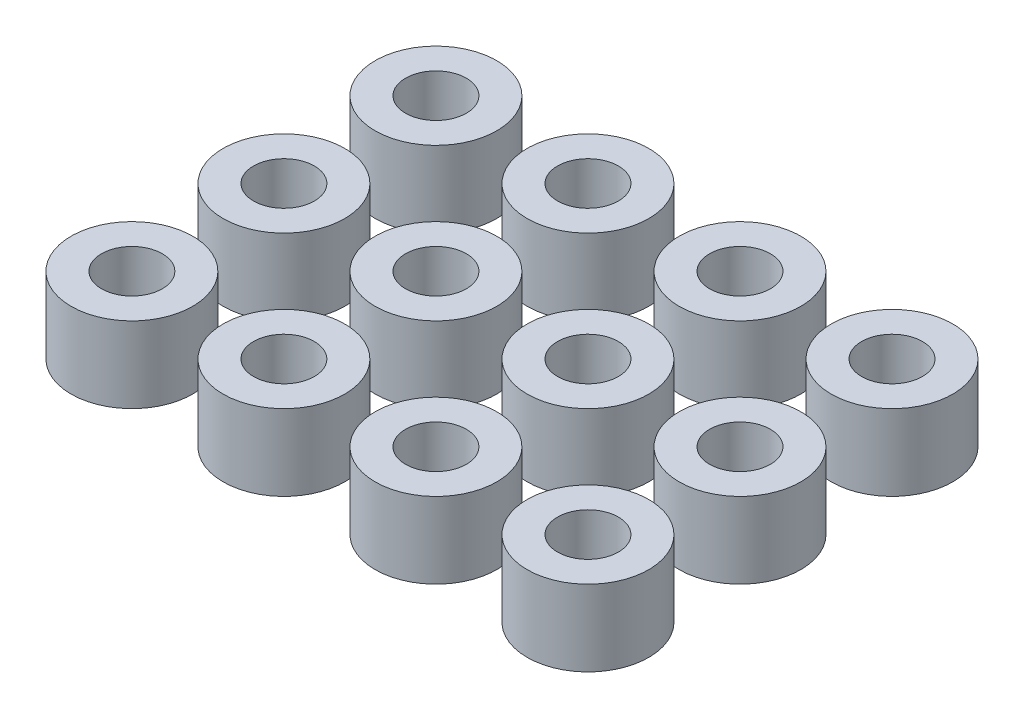
from build123d import *

# Parameters (mm, degrees)
SKETCH1_R              = 4
SKETCH1_R_2            = 2
BOSS_EXTRUDE1_DEPTH    = 5
BOSS_EXTRUDE1_2_DEPTH  = 5
BOSS_EXTRUDE1_3_DEPTH  = 5
BOSS_EXTRUDE1_4_DEPTH  = 5
BOSS_EXTRUDE1_5_DEPTH  = 5
BOSS_EXTRUDE1_6_DEPTH  = 5
BOSS_EXTRUDE1_7_DEPTH  = 5
BOSS_EXTRUDE1_8_DEPTH  = 5
BOSS_EXTRUDE1_9_DEPTH  = 5
BOSS_EXTRUDE1_10_DEPTH = 5
BOSS_EXTRUDE1_11_DEPTH = 5
BOSS_EXTRUDE1_12_DEPTH = 5


with BuildPart() as part:
    # Sketch1 → Boss-Extrude1 (new body)
    with BuildSketch(Plane(origin=(0, 0, 0), x_dir=(1, 0, 0), z_dir=(0, 1, 0))):
        with Locations((-15, -10)):
            Circle(SKETCH1_R)
        with Locations((-15, -10)):
            Circle(SKETCH1_R_2, mode=Mode.SUBTRACT)
    extrude(amount=BOSS_EXTRUDE1_DEPTH)


with BuildPart() as body_2:
    # Sketch1 → Boss-Extrude1 2 (new body)
    with BuildSketch(Plane(origin=(0, 0, 0), x_dir=(1, 0, 0), z_dir=(0, 1, 0))):
        with Locations((-5, -10)):
            Circle(SKETCH1_R)
        with Locations((-5, -10)):
            Circle(SKETCH1_R_2, mode=Mode.SUBTRACT)
    extrude(amount=BOSS_EXTRUDE1_2_DEPTH)


with BuildPart() as body_3:
    # Sketch1 → Boss-Extrude1 3 (new body)
    with BuildSketch(Plane(origin=(0, 0, 0), x_dir=(1, 0, 0), z_dir=(0, 1, 0))):
        with Locations((5, -10)):
            Circle(SKETCH1_R)
        with Locations((5, -10)):
            Circle(SKETCH1_R_2, mode=Mode.SUBTRACT)
    extrude(amount=BOSS_EXTRUDE1_3_DEPTH)


with BuildPart() as body_4:
    # Sketch1 → Boss-Extrude1 4 (new body)
    with BuildSketch(Plane(origin=(0, 0, 0), x_dir=(1, 0, 0), z_dir=(0, 1, 0))):
        with Locations((15, -10)):
            Circle(SKETCH1_R)
        with Locations((15, -10)):
            Circle(SKETCH1_R_2, mode=Mode.SUBTRACT)
    extrude(amount=BOSS_EXTRUDE1_4_DEPTH)


with BuildPart() as body_5:
    # Sketch1 → Boss-Extrude1 5 (new body)
    with BuildSketch(Plane(origin=(0, 0, 0), x_dir=(1, 0, 0), z_dir=(0, 1, 0))):
        with Locations((-5, 0)):
            Circle(SKETCH1_R)
        with Locations((-5, 0)):
            Circle(SKETCH1_R_2, mode=Mode.SUBTRACT)
    extrude(amount=BOSS_EXTRUDE1_5_DEPTH)


with BuildPart() as body_6:
    # Sketch1 → Boss-Extrude1 6 (new body)
    with BuildSketch(Plane(origin=(0, 0, 0), x_dir=(1, 0, 0), z_dir=(0, 1, 0))):
        with Locations((5, 0)):
            Circle(SKETCH1_R)
        with Locations((5, 0)):
            Circle(SKETCH1_R_2, mode=Mode.SUBTRACT)
    extrude(amount=BOSS_EXTRUDE1_6_DEPTH)


with BuildPart() as body_7:
    # Sketch1 → Boss-Extrude1 7 (new body)
    with BuildSketch(Plane(origin=(0, 0, 0), x_dir=(1, 0, 0), z_dir=(0, 1, 0))):
        with Locations((15, 0)):
            Circle(SKETCH1_R)
        with Locations((15, 0)):
            Circle(SKETCH1_R_2, mode=Mode.SUBTRACT)
    extrude(amount=BOSS_EXTRUDE1_7_DEPTH)


with BuildPart() as body_8:
    # Sketch1 → Boss-Extrude1 8 (new body)
    with BuildSketch(Plane(origin=(0, 0, 0), x_dir=(1, 0, 0), z_dir=(0, 1, 0))):
        with Locations((-5, 10)):
            Circle(SKETCH1_R)
        with Locations((-5, 10)):
            Circle(SKETCH1_R_2, mode=Mode.SUBTRACT)
    extrude(amount=BOSS_EXTRUDE1_8_DEPTH)


with BuildPart() as body_9:
    # Sketch1 → Boss-Extrude1 9 (new body)
    with BuildSketch(Plane(origin=(0, 0, 0), x_dir=(1, 0, 0), z_dir=(0, 1, 0))):
        with Locations((5, 10)):
            Circle(SKETCH1_R)
        with Locations((5, 10)):
            Circle(SKETCH1_R_2, mode=Mode.SUBTRACT)
    extrude(amount=BOSS_EXTRUDE1_9_DEPTH)


with BuildPart() as body_10:
    # Sketch1 → Boss-Extrude1 10 (new body)
    with BuildSketch(Plane(origin=(0, 0, 0), x_dir=(1, 0, 0), z_dir=(0, 1, 0))):
        with Locations((15, 10)):
            Circle(SKETCH1_R)
        with Locations((15, 10)):
            Circle(SKETCH1_R_2, mode=Mode.SUBTRACT)
    extrude(amount=BOSS_EXTRUDE1_10_DEPTH)


with BuildPart() as body_11:
    # Sketch1 → Boss-Extrude1 11 (new body)
    with BuildSketch(Plane(origin=(0, 0, 0), x_dir=(1, 0, 0), z_dir=(0, 1, 0))):
        with Locations((-15, 0)):
            Circle(SKETCH1_R)
        with Locations((-15, 0)):
            Circle(SKETCH1_R_2, mode=Mode.SUBTRACT)
    extrude(amount=BOSS_EXTRUDE1_11_DEPTH)


with BuildPart() as body_12:
    # Sketch1 → Boss-Extrude1 12 (new body)
    with BuildSketch(Plane(origin=(0, 0, 0), x_dir=(1, 0, 0), z_dir=(0, 1, 0))):
        with Locations((-15, 10)):
            Circle(SKETCH1_R)
        with Locations((-15, 10)):
            Circle(SKETCH1_R_2, mode=Mode.SUBTRACT)
    extrude(amount=BOSS_EXTRUDE1_12_DEPTH)


solid = Compound([part.part, body_2.part, body_3.part, body_4.part, body_5.part, body_6.part, body_7.part, body_8.part, body_9.part, body_10.part, body_11.part, body_12.part])
